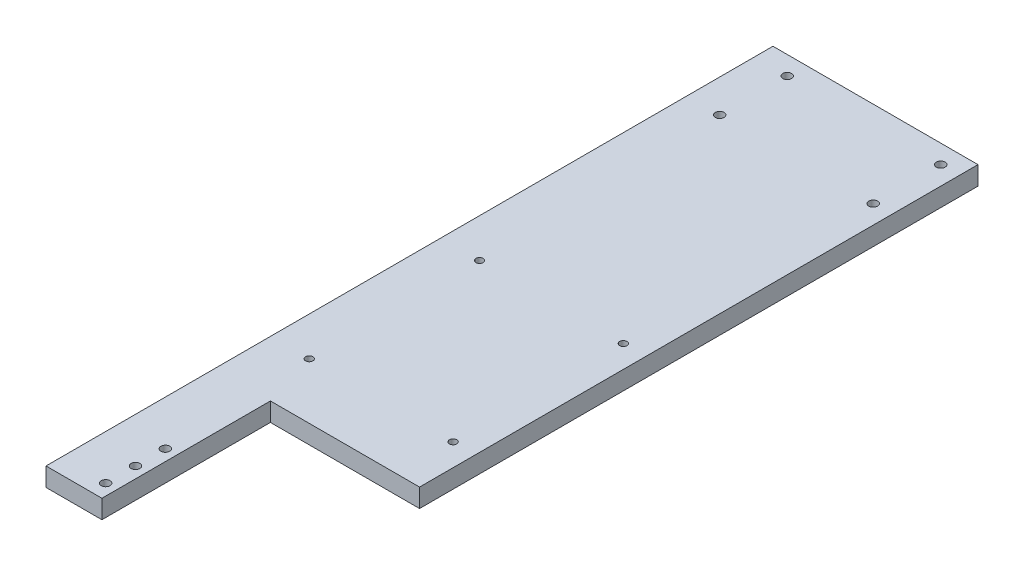
from build123d import *

# Parameters (mm, degrees)
SKETCH1_W           = 69.85
SKETCH1_H           = 247.65
BOSS_EXTRUDE1_DEPTH = 6.35
SKETCH2_W           = 50.8
SKETCH2_H           = 57.404
CUT_EXTRUDE1_DEPTH  = 7.35
SKETCH3_R           = 1.499997
CUT_EXTRUDE2_DEPTH  = 7.35
SKETCH4_R           = 1.499997
CUT_EXTRUDE3_DEPTH  = 7.35
SKETCH5_R           = 1.25
CUT_EXTRUDE4_DEPTH  = 7.35


with BuildPart() as part:
    # Sketch1 → Boss-Extrude1 (new body)
    with BuildSketch(Plane(origin=(0, 0, 0), x_dir=(1, 0, 0), z_dir=(0, 1, 0))):
        with Locations((34.925, 123.825)):
            Rectangle(SKETCH1_W, SKETCH1_H)
    extrude(amount=BOSS_EXTRUDE1_DEPTH)

    # Sketch2 → Cut-Extrude1 (cut, through all)
    with BuildSketch(Plane(origin=(0, 6.35, 0), x_dir=(1, 0, 0), z_dir=(0, 1, 0))):
        with Locations((44.45, 28.702)):
            Rectangle(SKETCH2_W, SKETCH2_H)
    extrude(amount=-CUT_EXTRUDE1_DEPTH, mode=Mode.SUBTRACT)

    # Sketch3 → Cut-Extrude2 (cut, through all)
    with BuildSketch(Plane(origin=(0, 6.35, 0), x_dir=(1, 0, 0), z_dir=(0, 1, 0))):
        with Locations((15.24, 5.08)):
            Circle(SKETCH3_R)
        with Locations((15.24, 25.4)):
            Circle(SKETCH3_R)
        with Locations((15.24, 15.24)):
            Circle(SKETCH3_R)
    extrude(amount=-CUT_EXTRUDE2_DEPTH, mode=Mode.SUBTRACT)

    # Sketch4 → Cut-Extrude3 (cut, through all)
    with BuildSketch(Plane(origin=(0, 6.35, 0), x_dir=(1, 0, 0), z_dir=(0, 1, 0))):
        with Locations((63.5, 241.3)):
            Circle(SKETCH4_R)
        with Locations((63.5, 218.3)):
            Circle(SKETCH4_R)
        with Locations((11.2, 218.3)):
            Circle(SKETCH4_R)
        with Locations((11.2, 241.3)):
            Circle(SKETCH4_R)
    extrude(amount=-CUT_EXTRUDE3_DEPTH, mode=Mode.SUBTRACT)

    # Sketch5 → Cut-Extrude4 (cut, through all)
    with BuildSketch(Plane(origin=(0, 6.35, 0), x_dir=(1, 0, 0), z_dir=(0, 1, 0))):
        with Locations((13.23, 134.454)):
            Circle(SKETCH5_R)
        with Locations((62.23, 134.454)):
            Circle(SKETCH5_R)
        with Locations((62.23, 76.454)):
            Circle(SKETCH5_R)
        with Locations((13.23, 76.454)):
            Circle(SKETCH5_R)
    extrude(amount=-CUT_EXTRUDE4_DEPTH, mode=Mode.SUBTRACT)


solid = part.part
